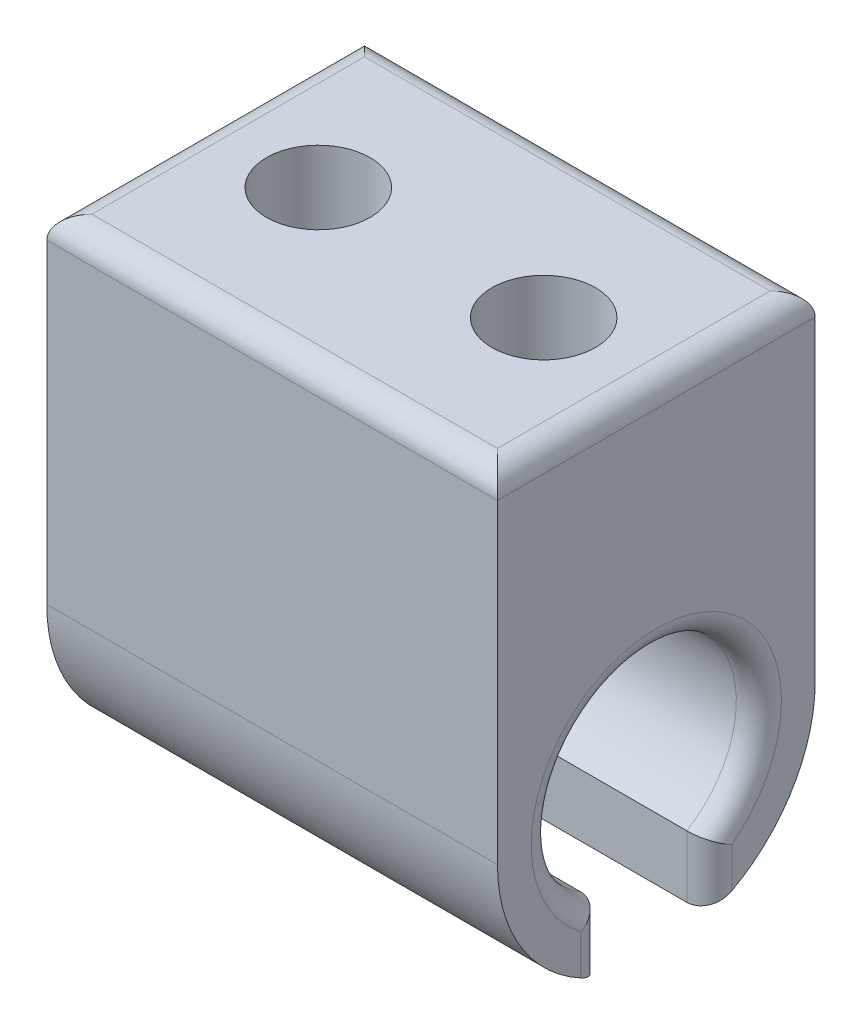
from build123d import *

# Parameters (mm, degrees)
SKETCH1_R           = 5.7785
BOSS_EXTRUDE1_DEPTH = 25.4
SKETCH2_R           = 2.921
CUT_EXTRUDE1_DEPTH  = 27.513623
SKETCH3_W           = 5.969
SKETCH3_H           = 4.005387026
CUT_EXTRUDE2_DEPTH  = 26.4000001
FILLET1_R           = 1.27
FILLET2_R           = 1.27


with BuildPart() as part:
    # Sketch1 → Boss-Extrude1 (new body)
    with BuildSketch(Plane(origin=(0, 0, 0), x_dir=(0, 0, -1), z_dir=(1, 0, 0))):
        with BuildLine():
            Line((-8.9535, 19.05), (-8.9535, 0))
            ThreePointArc((-8.9535, 0), (0, -8.9535), (8.9535, 0))
            Line((8.9535, 0), (8.9535, 19.05))
            Line((8.9535, 19.05), (-8.9535, 19.05))
        make_face()
        Circle(SKETCH1_R, mode=Mode.SUBTRACT)
    extrude(amount=BOSS_EXTRUDE1_DEPTH)

    # Sketch2 → Cut-Extrude1 (cut)
    with BuildSketch(Plane(origin=(0, 19.05, 0), x_dir=(1, 0, 0), z_dir=(0, 1, 0))):
        with Locations((6.35, 0)):
            Circle(SKETCH2_R)
        with Locations((19.05, 0)):
            Circle(SKETCH2_R)
    extrude(amount=-CUT_EXTRUDE1_DEPTH, mode=Mode.SUBTRACT)

    # Sketch3 → Cut-Extrude2 (cut, through all)
    with BuildSketch(Plane.ZY):
        with Locations((0, -6.950806487)):
            Rectangle(SKETCH3_W, SKETCH3_H)
    extrude(amount=-CUT_EXTRUDE2_DEPTH, mode=Mode.SUBTRACT)

    # Fillet1
    fillet1_edges = [part.edges().sort_by_distance(p)[0] for p in [
        (0, 5.031748975, 2.84122588),
        (0, -6.694776864, 2.9845),
        (25.4, 5.031748975, 2.84122588),
        (0, -6.694776864, -2.9845),
        (25.4, -6.694776864, -2.9845),
        (25.4, -6.694776864, 2.9845),
    ]]
    fillet(fillet1_edges, radius=FILLET1_R)

    # Fillet2
    fillet2_edges = [part.edges().sort_by_distance(p)[0] for p in [
        (12.7, 19.05, 8.9535),
        (12.7, 19.05, -8.9535),
        (25.4, 19.05, 0),
        (0, 19.05, 0),
    ]]
    fillet(fillet2_edges, radius=FILLET2_R)


solid = part.part
